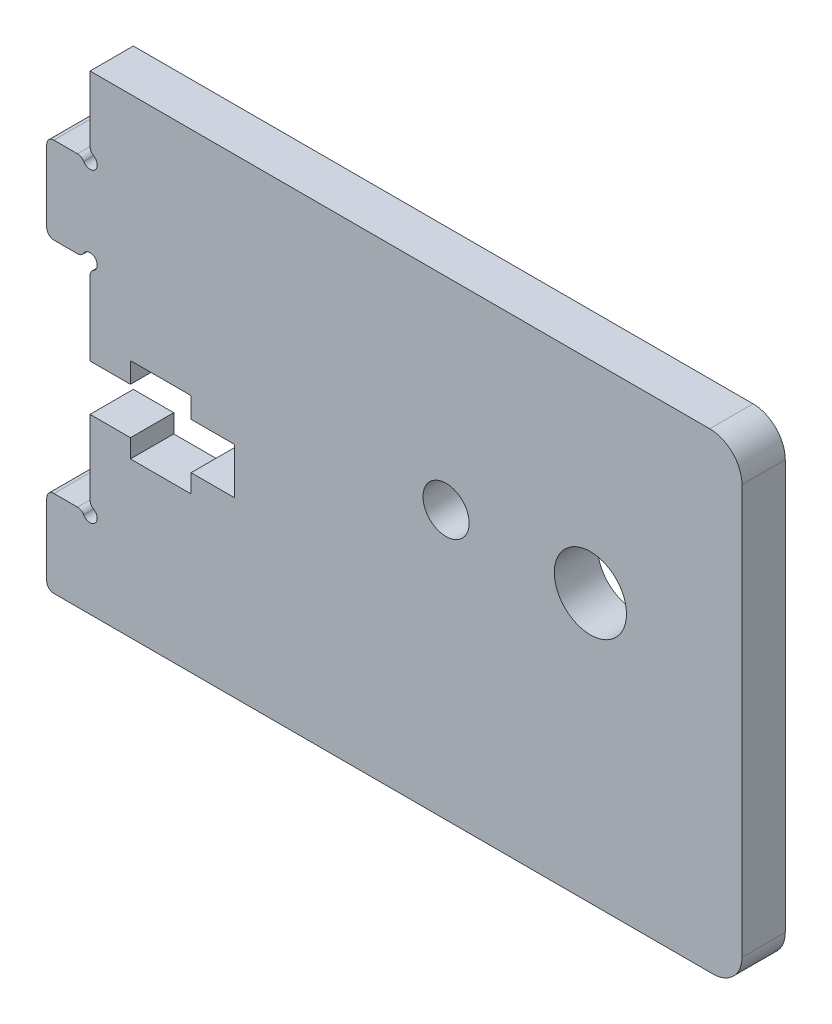
from build123d import *

# Parameters (mm, degrees)
SKETCH1_R           = 1.6
SKETCH1_R_2         = 2.5
BOSS_EXTRUDE1_DEPTH = 3


with BuildPart() as part:
    # Sketch1 → Boss-Extrude1 (new body)
    with BuildSketch(Plane.XY):
        with BuildLine():
            Line((168.027079905, 1038.043290918), (213.692404138, 1038.043292418))
            ThreePointArc((213.692404138, 1038.043292418), (215.106618088, 1038.62907792), (215.692405461, 1040.043291095))
            Line((215.692405461, 1040.043291095), (215.692425273, 1068.407217461))
            ThreePointArc((215.692425273, 1068.407217461), (215.037497189, 1069.988356706), (213.456358826, 1070.643286918))
            Line((213.456358826, 1070.643286918), (170.527157049, 1070.643286918))
            Line((170.527157049, 1070.643286918), (170.527154049, 1066.109317918))
            ThreePointArc((170.527154049, 1066.109317918), (170.594141198, 1065.85931758), (170.777154049, 1065.67630462))
            ThreePointArc((170.777154049, 1065.67630462), (170.880709235, 1064.889738733), (170.094142887, 1064.993290414))
            ThreePointArc((170.094142887, 1064.993290414), (169.911130301, 1065.176302052), (169.661131049, 1065.243288918))
            Line((169.661131049, 1065.243288918), (168.027102049, 1065.243288918))
            ThreePointArc((168.027102049, 1065.243288918), (167.673548658, 1065.096842309), (167.527102049, 1064.743288918))
            Line((167.527102049, 1064.743288918), (167.527102049, 1059.743291918))
            ThreePointArc((167.527102049, 1059.743291918), (167.673545881, 1059.389741498), (168.027094, 1059.243292111))
            Line((168.027094, 1059.243292111), (169.661121, 1059.243294985))
            ThreePointArc((169.661121, 1059.243294985), (169.911120776, 1059.310282365), (170.094133317, 1059.493294952))
            ThreePointArc((170.094133317, 1059.493294952), (170.880698604, 1059.596848318), (170.77714747, 1058.810282737))
            ThreePointArc((170.77714747, 1058.810282737), (170.594135891, 1058.627270291), (170.527148933, 1058.37727121))
            Line((170.527148933, 1058.37727121), (170.527145536, 1053.243292145))
            Line((170.527145536, 1053.243292145), (173.327145536, 1053.243292145))
            Line((173.327145536, 1053.243292145), (173.327146479, 1054.668300832))
            Line((173.327146479, 1054.668300832), (177.527142575, 1054.668300832))
            Line((177.527142575, 1054.668300832), (177.527142575, 1053.243290914))
            Line((177.527142575, 1053.243290914), (180.527142575, 1053.243292145))
            Line((180.527142575, 1053.243292145), (180.527142575, 1050.043292145))
            Line((180.527142575, 1050.043292145), (177.527142575, 1050.043292145))
            Line((177.527142575, 1050.043292145), (177.527142575, 1048.768300832))
            Line((177.527142575, 1048.768300832), (173.327142575, 1048.768300832))
            Line((173.327142575, 1048.768300832), (173.327143418, 1050.043292145))
            Line((173.327143418, 1050.043292145), (170.527143418, 1050.043292145))
            Line((170.527143418, 1050.043292145), (170.527140021, 1044.909316322))
            ThreePointArc((170.527140021, 1044.909316322), (170.594127154, 1044.659316277), (170.777139735, 1044.476303455))
            ThreePointArc((170.777139735, 1044.476303455), (170.8806944, 1043.689737499), (170.094128121, 1043.793289701))
            ThreePointArc((170.094128121, 1043.793289701), (169.911115656, 1043.97630146), (169.661116448, 1044.043288491))
            Line((169.661116448, 1044.043288491), (168.027087448, 1044.043289572))
            ThreePointArc((168.027087448, 1044.043289572), (167.673533961, 1043.896843197), (167.527087117, 1043.543289903))
            Line((167.527087117, 1043.543289903), (167.527083809, 1038.543292903))
            ThreePointArc((167.527083809, 1038.543292903), (167.673528336, 1038.189739609), (168.027079905, 1038.043290918))
        make_face()
        with Locations((195.192419253, 1056.643286172)):
            Circle(SKETCH1_R, mode=Mode.SUBTRACT)
        with Locations((205.192419253, 1056.643286172)):
            Circle(SKETCH1_R_2, mode=Mode.SUBTRACT)
    extrude(amount=BOSS_EXTRUDE1_DEPTH)


solid = part.part
